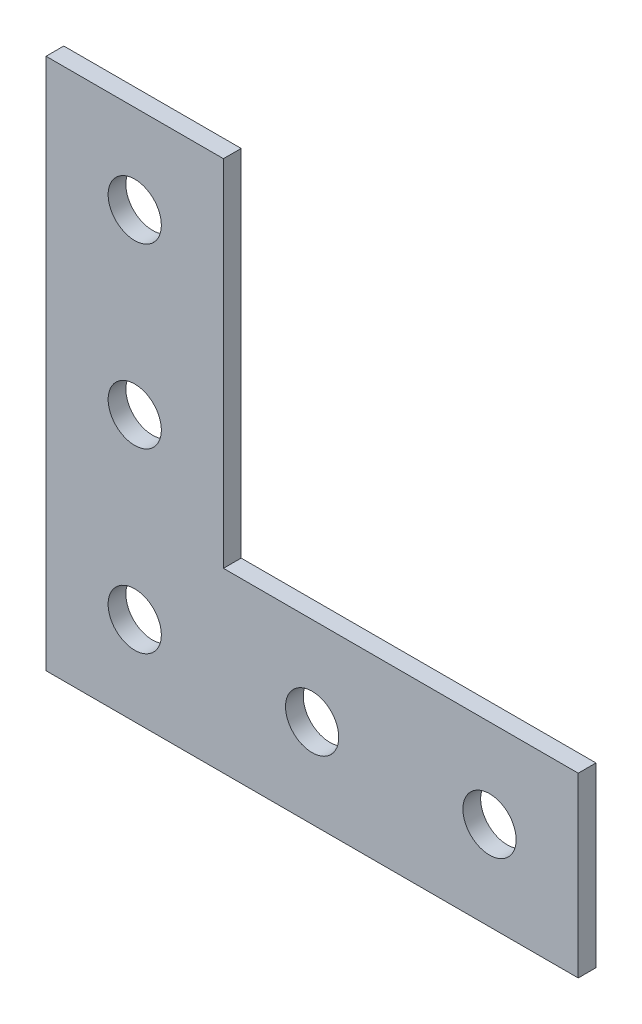
from build123d import *

# Parameters (mm, degrees)
BOSS_EXTRU_1_DEPTH      = 1
ESQUISSE2_R             = 1.5
ENL_V_MAT_EXTRU_1_DEPTH = 2


with BuildPart() as part:
    # Esquisse1 → Boss.-Extru.1 (new body)
    with BuildSketch(Plane.XY):
        Polygon((0, 0), (30, 0), (30, 10), (10, 10), (10, 30), (0, 30), align=None)
    extrude(amount=BOSS_EXTRU_1_DEPTH)

    # Esquisse2 → Enlèv. mat.-Extru.1 (cut, through all)
    with BuildSketch(Plane.XY.offset(1)):
        with Locations((5, 5)):
            Circle(ESQUISSE2_R)
        with Locations((5, 15)):
            Circle(ESQUISSE2_R)
        with Locations((5, 25)):
            Circle(ESQUISSE2_R)
        with Locations((15, 5)):
            Circle(ESQUISSE2_R)
        with Locations((25, 5)):
            Circle(ESQUISSE2_R)
    extrude(amount=-ENL_V_MAT_EXTRU_1_DEPTH, mode=Mode.SUBTRACT)


solid = part.part
